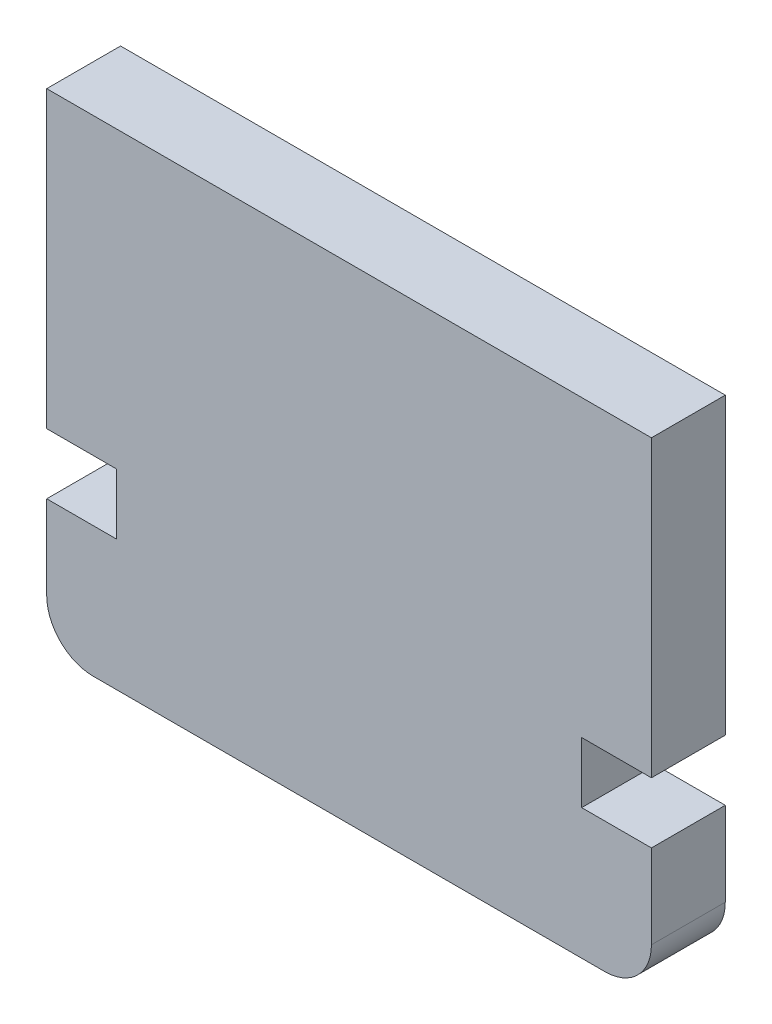
from build123d import *

# Parameters (mm, degrees)
BOSS_EXTRUDE1_DEPTH = 3.175


with BuildPart() as part:
    # Sketch1 → Boss-Extrude1 (new body)
    with BuildSketch(Plane.XY):
        with BuildLine():
            Line((-27.95, 18.625), (-1.95, 18.625))
            Line((-1.95, 18.625), (-1.95, 5.963704675))
            Line((-1.95, 5.963704675), (-4.95, 5.963704675))
            Line((-4.95, 5.963704675), (-4.95, 3.353294588))
            Line((-4.95, 3.353294588), (-1.95, 3.353294588))
            Line((-1.95, 3.353294588), (-1.95, 2.795))
            Line((-1.95, 2.795), (-1.95, -0.255))
            ThreePointArc((-1.95, -0.255), (-2.535786438, -1.669213562), (-3.95, -2.255))
            Line((-3.95, -2.255), (-25.95, -2.255))
            ThreePointArc((-25.95, -2.255), (-27.364213562, -1.669213562), (-27.95, -0.255))
            Line((-27.95, -0.255), (-27.95, 2.795))
            Line((-27.95, 2.795), (-27.95, 3.353294588))
            Line((-27.95, 3.353294588), (-24.95, 3.353294588))
            Line((-24.95, 3.353294588), (-24.95, 5.963704675))
            Line((-24.95, 5.963704675), (-27.95, 5.963704675))
            Line((-27.95, 5.963704675), (-27.95, 18.625))
        make_face()
    extrude(amount=BOSS_EXTRUDE1_DEPTH)


solid = part.part
